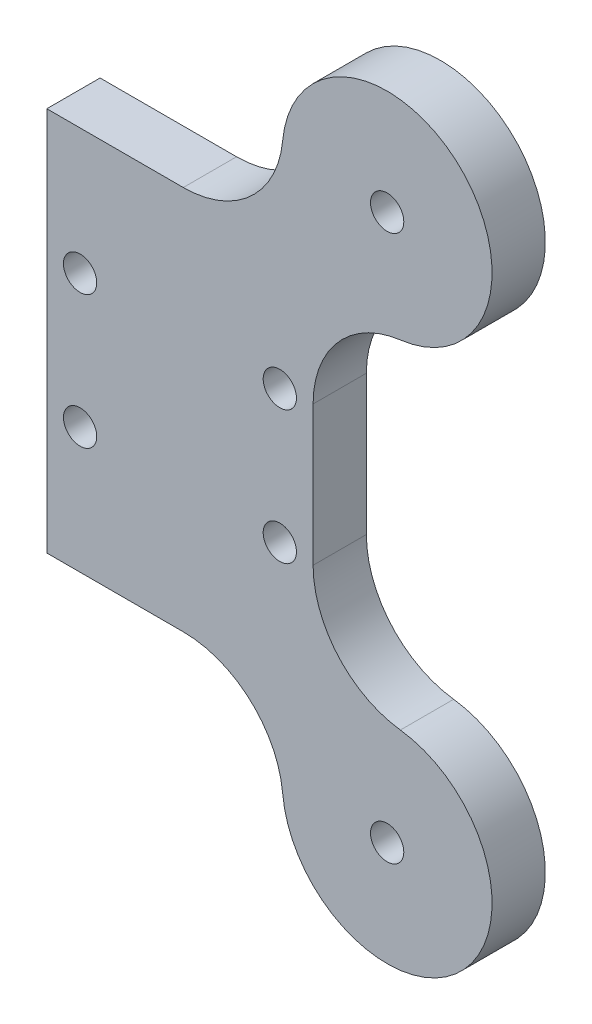
from build123d import *

# Parameters (mm, degrees)
SKETCH1_R            = 1.25
BOSS_EXTRUDE1_DEPTH  = 4
FILLET1_R            = 7.5
FILLET1_OF_MIRROR1_R = 7.5


with BuildPart() as part:
    # Sketch1 → Boss-Extrude1 (new body)
    with BuildSketch(Plane.XY):
        with BuildLine():
            Line((-10, -14.45), (7.681, -14.45))
            Line((7.681, -14.45), (7.681, -20.50229958))
            ThreePointArc((7.681, -20.50229958), (21.133001436, -26.074301016), (15.561, -12.62229958))
            Line((15.561, -12.62229958), (10, -12.62229958))
            Line((10, -12.62229958), (10, 0))
            Line((10, 0), (-10, 0))
            Line((-10, 0), (-10, -14.45))
        make_face()
        with Locations((-7.5, -5)):
            Circle(SKETCH1_R, mode=Mode.SUBTRACT)
        with Locations((7.5, -5)):
            Circle(SKETCH1_R, mode=Mode.SUBTRACT)
        with Locations((15.561, -20.50229958)):
            Circle(SKETCH1_R, mode=Mode.SUBTRACT)
    boss_extrude1 = extrude(amount=BOSS_EXTRUDE1_DEPTH)

    # Fillet1
    fillet1_edges = [part.edges().sort_by_distance(p)[0] for p in [
        (7.681, -14.45, 2),
        (10, -12.62229958, 2),
    ]]
    fillet(fillet1_edges, radius=FILLET1_R)

    # Mirror1: Boss-Extrude1 across plane
    add(boss_extrude1.mirror(Plane(origin=(-10, 0, 4), x_dir=(0, 0, 1), z_dir=(0, 1, 0))))

    # Fillet1 of Mirror1
    fillet1_of_mirror1_edges = [part.edges().sort_by_distance(p)[0] for p in [
        (7.681, 14.45, 2),
        (10, 12.62229958, 2),
    ]]
    fillet(fillet1_of_mirror1_edges, radius=FILLET1_OF_MIRROR1_R)


solid = part.part
